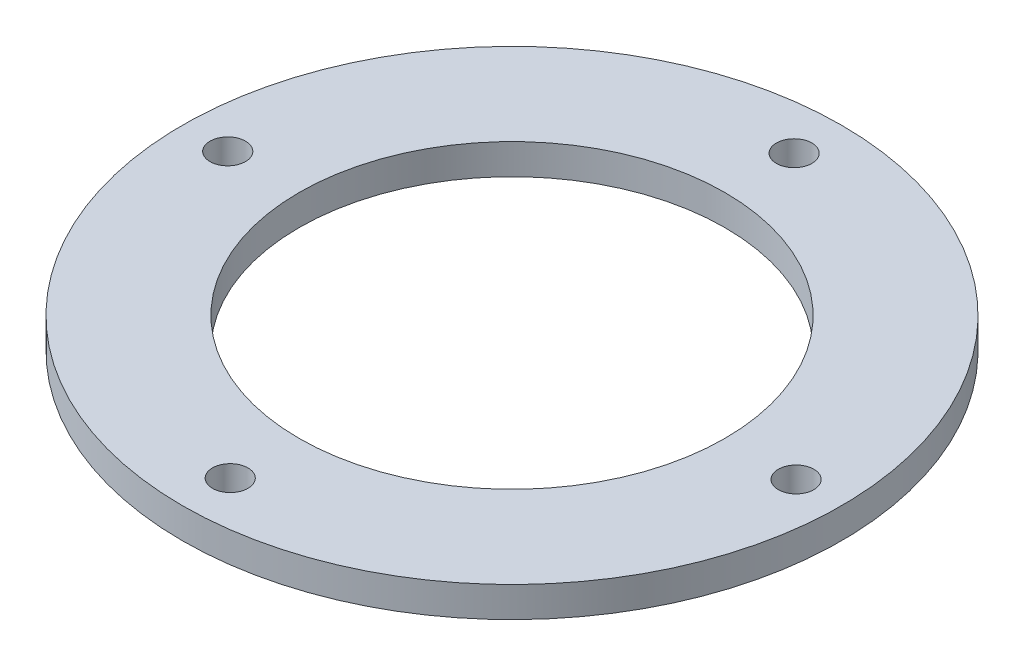
from build123d import *

# Parameters (mm, degrees)
SKETCH1_R                = 32.5
SKETCH1_R_2              = 21
BOSS_EXTRUDE2_DEPTH      = 3
SKETCH2_R                = 1.75
CUT_EXTRUDE2_DEPTH       = 1
CUT_EXTRUDE2_DEPTH_BACK  = 4
SKETCH5_R                = 1.75
CUT_EXTRUDE4_DEPTH       = 1
CUT_EXTRUDE4_DEPTH_BACK  = 4
SKETCH13_R               = 1.75
CUT_EXTRUDE12_DEPTH      = 1
CUT_EXTRUDE12_DEPTH_BACK = 4


with BuildPart() as part:
    # Sketch1 → Boss-Extrude2 (new body)
    with BuildSketch(Plane(origin=(0, 0, 0), x_dir=(1, 0, 0), z_dir=(0, 1, 0))):
        Circle(SKETCH1_R)
        Circle(SKETCH1_R_2, mode=Mode.SUBTRACT)
    extrude(amount=BOSS_EXTRUDE2_DEPTH)

    # Sketch2 → Cut-Extrude2 (cut, two sides)
    with BuildSketch(Plane(origin=(0, 3, 0), x_dir=(1, 0, 0), z_dir=(0, 1, 0))) as cut_extrude2_sk:
        with Locations((0, -27.788884535)):
            Circle(SKETCH2_R)
    extrude(amount=CUT_EXTRUDE2_DEPTH, mode=Mode.SUBTRACT)
    extrude(cut_extrude2_sk.sketch, amount=-CUT_EXTRUDE2_DEPTH_BACK, mode=Mode.SUBTRACT)

    # Sketch5 → Cut-Extrude4 (cut, two sides)
    with BuildSketch(Plane(origin=(0, 3, 0), x_dir=(1, 0, 0), z_dir=(0, 1, 0))) as cut_extrude4_sk:
        with Locations((0.057759675, 27.766269398)):
            Circle(SKETCH5_R)
    extrude(amount=CUT_EXTRUDE4_DEPTH, mode=Mode.SUBTRACT)
    extrude(cut_extrude4_sk.sketch, amount=-CUT_EXTRUDE4_DEPTH_BACK, mode=Mode.SUBTRACT)

    # Sketch13 → Cut-Extrude12 (cut, two sides)
    with BuildSketch(Plane(origin=(0, 3, 0), x_dir=(1, 0, 0), z_dir=(0, 1, 0))) as cut_extrude12_sk:
        with Locations((-28.027387252, -0.003979104)):
            Circle(SKETCH13_R)
        with Locations((28.01619309, 0)):
            Circle(SKETCH13_R)
    extrude(amount=CUT_EXTRUDE12_DEPTH, mode=Mode.SUBTRACT)
    extrude(cut_extrude12_sk.sketch, amount=-CUT_EXTRUDE12_DEPTH_BACK, mode=Mode.SUBTRACT)


solid = part.part
